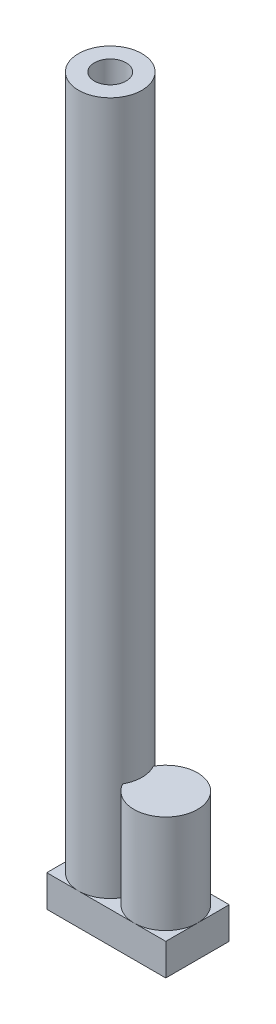
from build123d import *

# Parameters (mm, degrees)
SKETCH1_R           = 20
BOSS_EXTRUDE1_DEPTH = 457
SKETCH2_R           = 10
CUT_EXTRUDE1_DEPTH  = 526
SKETCH6_R           = 20
BOSS_EXTRUDE4_DEPTH = 82
SKETCH7_W           = 75
SKETCH7_H           = 40
BOSS_EXTRUDE5_DEPTH = 20


with BuildPart() as part:
    # Sketch1 → Boss-Extrude1 (new body)
    with BuildSketch(Plane(origin=(0, 0, 0), x_dir=(1, 0, 0), z_dir=(0, 1, 0))):
        Circle(SKETCH1_R)
    extrude(amount=BOSS_EXTRUDE1_DEPTH)

    # Sketch2 → Cut-Extrude1 (cut)
    with BuildSketch(Plane(origin=(0, 457, 0), x_dir=(1, 0, 0), z_dir=(0, 1, 0))):
        Circle(SKETCH2_R)
    extrude(amount=-CUT_EXTRUDE1_DEPTH, mode=Mode.SUBTRACT)

    # Sketch6 → Boss-Extrude4 (add)
    with BuildSketch(Plane.XZ):
        with Locations((35, 0)):
            Circle(SKETCH6_R)
    extrude(amount=-BOSS_EXTRUDE4_DEPTH)

    # Sketch7 → Boss-Extrude5 (add)
    with BuildSketch(Plane.XZ):
        with Locations((17.5, 0)):
            Rectangle(SKETCH7_W, SKETCH7_H)
    extrude(amount=-BOSS_EXTRUDE5_DEPTH)


solid = part.part
